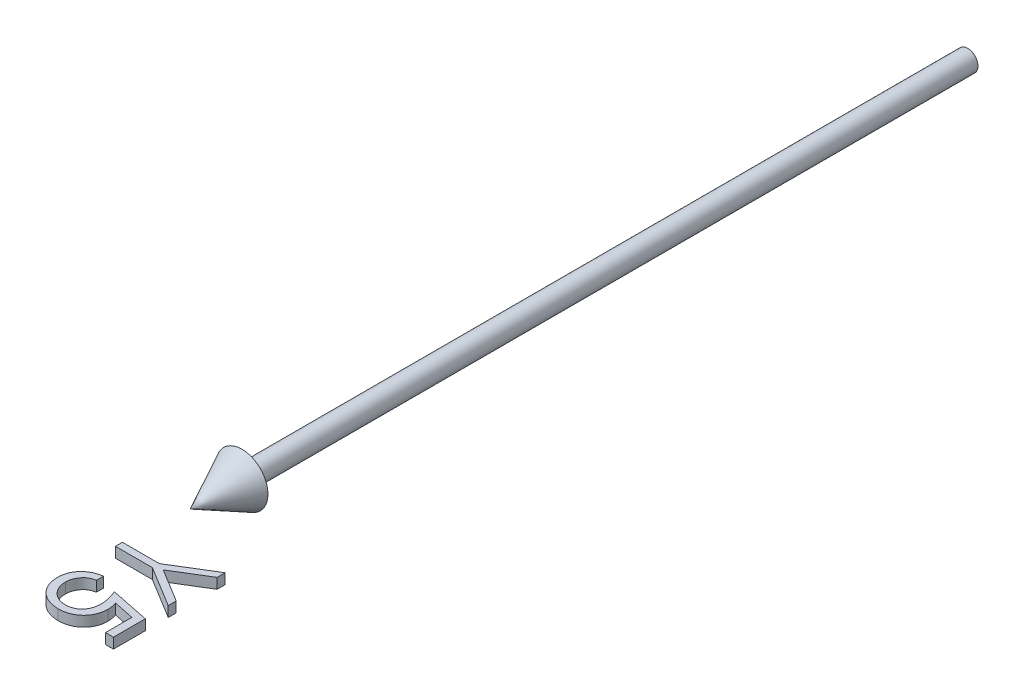
from build123d import *

# Parameters (mm, degrees)
BOSS_EXTRUDE1_DEPTH        = 1
BOSS_EXTRUDE1_DEPTH_BACK   = 1
BOSS_EXTRUDE1_2_DEPTH      = 1
BOSS_EXTRUDE1_2_DEPTH_BACK = 1


with BuildPart() as part:
    # Sketch2 → Revolve1 (revolve)
    with BuildSketch(Plane(origin=(0, 0, 0), x_dir=(1, 0, 0), z_dir=(0, 1, 0))):
        Polygon((0, -150), (5, -140), (2, -140), (2, 0), (0, 0), align=None)
    revolve(axis=Axis((0, 0, -41.949952025), (0, 0, 1)))


with BuildPart() as body_2:
    # Sketch3 → Boss-Extrude1 (new, two sides: drawn at the far end of the back side and taken through both)
    with BuildSketch(Plane(origin=(0, 0, 0), x_dir=(1, 0, 0), z_dir=(0, 1, 0)).offset(-BOSS_EXTRUDE1_DEPTH_BACK)):
        Polygon((15, -158.269230769), (15, -159.810697115), (8.5546875, -163.753004808), (15, -167.689302885), (15, -169.230769231), (7.130408654, -164.423076923), (0, -164.423076923), (0, -163.076923077), (7.130408654, -163.076923077), align=None)
    extrude(amount=BOSS_EXTRUDE1_DEPTH + BOSS_EXTRUDE1_DEPTH_BACK)


with BuildPart() as body_3:
    # Sketch3 → Boss-Extrude1 2 (new, two sides: drawn at the far end of the back side and taken through both)
    with BuildSketch(Plane(origin=(0, 0, 0), x_dir=(1, 0, 0), z_dir=(0, 1, 0)).offset(-BOSS_EXTRUDE1_2_DEPTH_BACK)):
        with BuildLine():
            Line((15, -179.807692308), (13.461538462, -179.807692308))
            Line((13.461538462, -179.807692308), (13.461538462, -174.705528846))
            Line((13.461538462, -174.705528846), (9.516225962, -173.897235577))
            add(Edge.make_bspline(
                [(9.516225962, -173.897235577), (9.560069984, -174.056046467), (9.645010842, -174.363717449), (9.739321287, -174.817831139), (9.79617319, -175.248940583), (9.803935949, -175.52869217), (9.807692308, -175.6640625)],
                knots=[0, 0, 0, 0, 1.100273476, 2.13160584, 3.095893838, 4, 4, 4, 4], degree=3))
            add(Edge.make_bspline(
                [(9.807692308, -175.6640625), (9.80406592, -175.831563664), (9.796935536, -176.160912801), (9.728498237, -176.642802217), (9.620706778, -177.102770502), (9.470367987, -177.540031781), (9.27688397, -177.955527868), (9.038322224, -178.346938443), (8.756332859, -178.71648177), (8.433636595, -179.059272633), (8.078046752, -179.36977016), (7.69696552, -179.643847295), (7.29004627, -179.87179102), (6.859088372, -180.059323742), (6.40481492, -180.208112848), (5.923863394, -180.30741536), (5.420501794, -180.373464937), (5.07634109, -180.380849655), (4.900841346, -180.384615385)],
                knots=[0, 0, 0, 0, 1.052772836, 2.070014431, 3.053871312, 4.019926262, 4.972333346, 5.930471369, 6.896690565, 7.89035727, 8.885779078, 9.861050232, 10.836829716, 11.812751485, 12.812646763, 13.836748493, 14.896881366, 16, 16, 16, 16], degree=3))
            add(Edge.make_bspline(
                [(4.900841346, -180.384615385), (4.778603099, -180.381765446), (4.535778548, -180.376104083), (4.175162896, -180.347304507), (3.82217058, -180.291886664), (3.476806888, -180.217376289), (3.139533541, -180.121050596), (2.810473221, -180.00317501), (2.488612692, -179.864228754), (2.173930875, -179.707355138), (1.876128909, -179.525881439), (1.590609774, -179.334720075), (1.327881174, -179.1229659), (1.078351765, -178.900871002), (0.851820957, -178.659554718), (0.638594518, -178.406507121), (0.447934566, -178.135789814), (0.272570453, -177.852249643), (0.115556237, -177.556065406), (-0.015421666, -177.244233857), (-0.130224929, -176.923600511), (-0.223583551, -176.591307598), (-0.296016348, -176.247998871), (-0.3453421, -175.89249212), (-0.381230877, -175.526571213), (-0.383479521, -175.278535958), (-0.384615385, -175.153245192)],
                knots=[0, 0, 0, 0, 1.05623316, 2.098192244, 3.122504159, 4.140841222, 5.148757784, 6.150489607, 7.158294732, 8.176043417, 9.185147859, 10.169157858, 11.142149047, 12.097904048, 13.0527185, 13.998867679, 14.954465986, 15.910220987, 16.877849176, 17.847023716, 18.829548819, 19.818454515, 20.826519638, 21.858115382, 22.918063636, 24, 24, 24, 24], degree=3))
            add(Edge.make_bspline(
                [(-0.384615385, -175.153245192), (-0.381654391, -175.003784601), (-0.375828986, -174.709738543), (-0.314896318, -174.278933505), (-0.227608888, -173.864451862), (-0.096359784, -173.46957387), (0.068338734, -173.090967937), (0.275171288, -172.733674031), (0.512831306, -172.390669376), (0.789518858, -172.071276433), (1.094777245, -171.775442729), (1.4224906, -171.506555591), (1.773961963, -171.27074318), (2.146199136, -171.067043165), (2.539842613, -170.893540967), (2.956070317, -170.757174261), (3.392788381, -170.64712876), (3.693445765, -170.600570611), (3.846153846, -170.576923077)],
                knots=[0, 0, 0, 0, 1.046825758, 2.059506013, 3.044032586, 4.011925612, 4.970610144, 5.93275819, 6.900651216, 7.891265644, 8.889116719, 9.876966323, 10.858259055, 11.851035124, 12.847502422, 13.86866322, 14.9174643, 16, 16, 16, 16], degree=3))
            Line((3.846153846, -170.576923077), (3.846153846, -171.923076923))
            add(Edge.make_bspline(
                [(3.846153846, -171.923076923), (3.703098259, -171.956178466), (3.428137478, -172.01980147), (3.04204192, -172.159817802), (2.69668325, -172.329958206), (2.391735429, -172.53687613), (2.12441618, -172.778712967), (1.88413982, -173.052693328), (1.670243081, -173.362720419), (1.490802042, -173.707096607), (1.337990992, -174.070626836), (1.236183362, -174.451045596), (1.164611935, -174.838067395), (1.157446733, -175.099831414), (1.153846154, -175.231370192)],
                knots=[0, 0, 0, 0, 1.136389429, 2.184203582, 3.172920998, 4.111012962, 5.028380909, 5.957351669, 6.927793475, 7.937618031, 8.960409703, 9.974842029, 10.982339866, 12, 12, 12, 12], degree=3))
            add(Edge.make_bspline(
                [(1.153846154, -175.231370192), (1.157363773, -175.359763526), (1.164289995, -175.612571049), (1.217600047, -175.984619849), (1.299703924, -176.343817882), (1.422574731, -176.686620839), (1.571909239, -177.019027437), (1.763545278, -177.332629311), (1.984088214, -177.636498784), (2.236759486, -177.921190785), (2.515201034, -178.181931282), (2.812961292, -178.412314658), (3.13060492, -178.604215716), (3.462632718, -178.765933325), (3.812683677, -178.888733177), (4.179117285, -178.976337382), (4.562838629, -179.027779063), (4.824564242, -179.034855549), (4.957932692, -179.038461538)],
                knots=[0, 0, 0, 0, 1.027316725, 2.022795036, 3.002884548, 3.971462791, 4.93288096, 5.914575861, 6.907176829, 7.935150275, 8.956128384, 9.956726525, 10.942570165, 11.921478529, 12.907843606, 13.90538589, 14.932640048, 16, 16, 16, 16], degree=3))
            add(Edge.make_bspline(
                [(4.957932692, -179.038461538), (5.078329844, -179.036094025), (5.314125191, -179.031457297), (5.657578768, -178.979931878), (5.984910027, -178.90775276), (6.29319175, -178.796930932), (6.58693828, -178.660001159), (6.859862365, -178.486279367), (7.118975898, -178.287697464), (7.353752503, -178.055103129), (7.571902904, -177.801468893), (7.757597535, -177.52090705), (7.913889203, -177.219816997), (8.048747155, -176.901683536), (8.14560886, -176.558978672), (8.218327983, -176.198478299), (8.260393931, -175.816292553), (8.26623058, -175.554989583), (8.269230769, -175.420673077)],
                knots=[0, 0, 0, 0, 1.045726679, 2.048034203, 3.01323695, 3.95502507, 4.889743367, 5.8246644, 6.761650845, 7.722168973, 8.692072792, 9.66525385, 10.638902184, 11.638179751, 12.663148338, 13.728659964, 14.832472288, 16, 16, 16, 16], degree=3))
            add(Edge.make_bspline(
                [(8.269230769, -175.420673077), (8.266827016, -175.30339655), (8.26190616, -175.063313293), (8.223180046, -174.694185696), (8.163603645, -174.307975981), (8.07773504, -173.903184759), (7.970221633, -173.480922911), (7.835950868, -173.040488208), (7.68128788, -172.581870009), (7.561325997, -172.273187122), (7.5, -172.115384615)],
                knots=[0, 0, 0, 0, 0.824638674, 1.688163388, 2.607705698, 3.571998603, 4.597075385, 5.671199175, 6.809488238, 8, 8, 8, 8], degree=3))
            Line((7.5, -172.115384615), (15, -173.653846154))
            Line((15, -173.653846154), (15, -179.807692308))
        make_face()
    extrude(amount=BOSS_EXTRUDE1_2_DEPTH + BOSS_EXTRUDE1_2_DEPTH_BACK)


solid = Compound([part.part, body_2.part, body_3.part])
